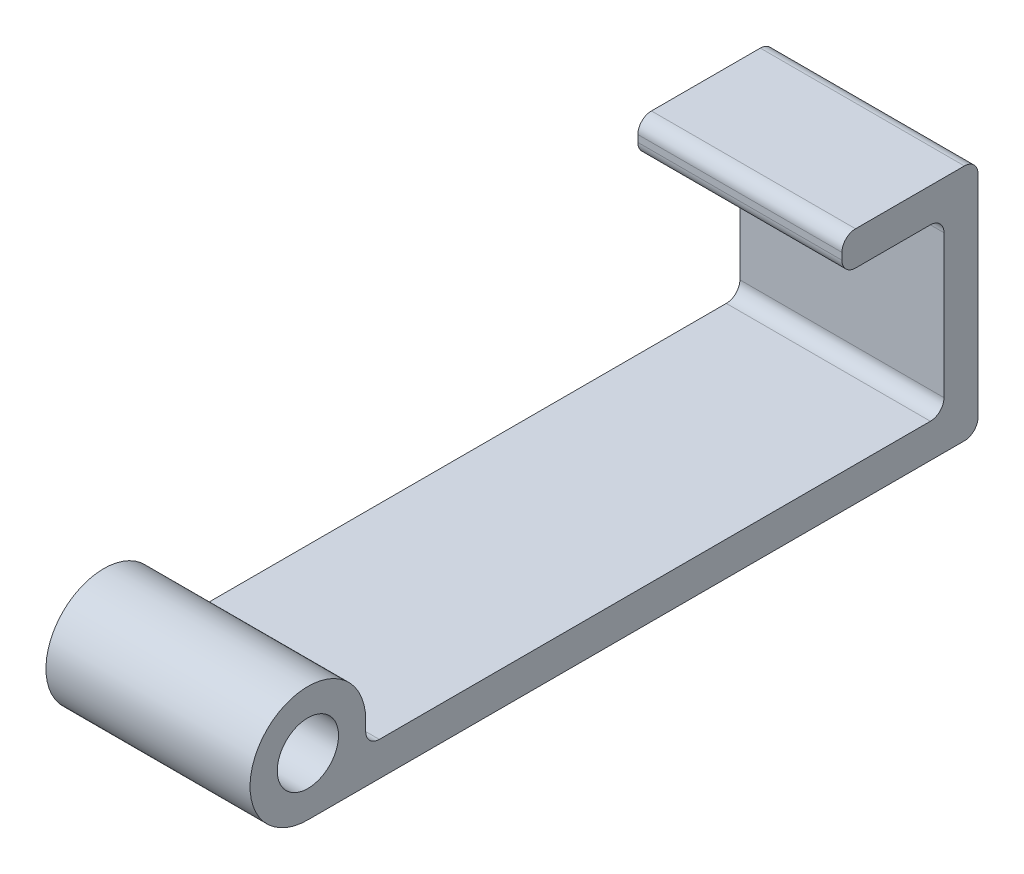
from build123d import *

# Parameters (mm, degrees)
SKETCH1_W           = 30
SKETCH1_H           = 85
BOSS_EXTRUDE1_DEPTH = 5
SKETCH2_R           = 4.5
BOSS_EXTRUDE2_DEPTH = 30
FILLET1_R           = 2


with BuildPart() as part:
    # Sketch1 → Boss-Extrude1 (new body)
    with BuildSketch(Plane(origin=(0, 0, 0), x_dir=(1, 0, 0), z_dir=(0, 1, 0))):
        Rectangle(SKETCH1_W, SKETCH1_H)
    extrude(amount=BOSS_EXTRUDE1_DEPTH)

    # Sketch2 → Boss-Extrude2 (add)
    with BuildSketch(Plane(origin=(15, 0, 0), x_dir=(0, 0, -1), z_dir=(1, 0, 0))):
        with BuildLine():
            Line((-42.5, 5), (-42.5, 8.5))
            ThreePointArc((-42.5, 8.5), (-57.01040764, 14.51040764), (-51, 0))
            Line((-51, 0), (-42.5, 0))
            Line((-42.5, 0), (-42.5, 5))
        make_face()
        with Locations((-51, 8.5)):
            Circle(SKETCH2_R, mode=Mode.SUBTRACT)
        Polygon((42.5, 5), (42.5, 0), (47.5, 0), (47.5, 30), (42.5, 30), align=None)
        Polygon((42.5, 30), (47.5, 30), (47.5, 35), (27.5, 35), (27.5, 30), align=None)
    extrude(amount=-BOSS_EXTRUDE2_DEPTH)

    # Fillet1
    fillet1_edges = [part.edges().sort_by_distance(p)[0] for p in [
        (0, 5, -42.5),
        (0, 0, -47.5),
        (0, 30, -42.5),
        (0, 30, -27.5),
        (0, 35, -27.5),
        (0, 35, -47.5),
        (0, 5, 42.5),
    ]]
    fillet(fillet1_edges, radius=FILLET1_R)


solid = part.part
